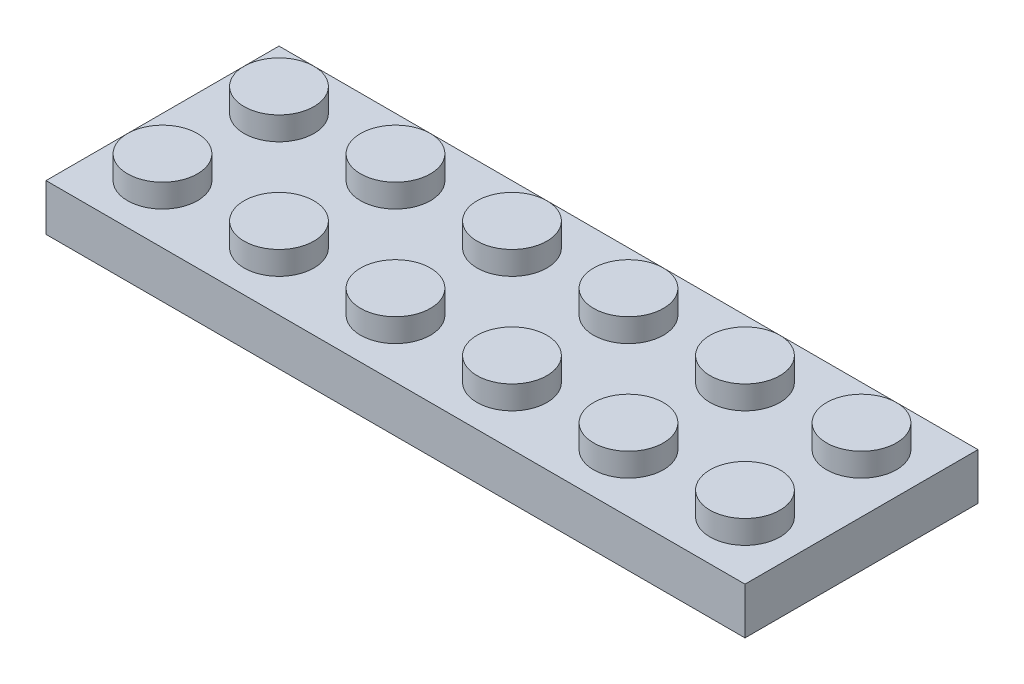
from build123d import *

# Parameters (mm, degrees)
SKETCH1_R              = 1.5
BOSS_EXTRUDE1_DEPTH    = 2
BOSS_EXTRUDE1_2_DEPTH  = 2
BOSS_EXTRUDE1_3_DEPTH  = 2
BOSS_EXTRUDE1_4_DEPTH  = 2
BOSS_EXTRUDE1_5_DEPTH  = 2
BOSS_EXTRUDE1_6_DEPTH  = 2
BOSS_EXTRUDE1_7_DEPTH  = 2
BOSS_EXTRUDE1_8_DEPTH  = 2
BOSS_EXTRUDE1_9_DEPTH  = 2
BOSS_EXTRUDE1_10_DEPTH = 2
BOSS_EXTRUDE1_11_DEPTH = 2
BOSS_EXTRUDE1_12_DEPTH = 2
SKETCH1_3_W            = 30
SKETCH1_3_H            = 10
BOSS_EXTRUDE2_DEPTH    = 1
SKETCH1_4_W            = 30
SKETCH1_4_H            = 10
SKETCH1_4_W_2          = 28
SKETCH1_4_H_2          = 8
SKETCH1_4_R            = 2.035533906
SKETCH1_4_R_2          = 1.5
BOSS_EXTRUDE3_DEPTH    = 1


with BuildPart() as part:
    # Sketch1 → Boss-Extrude1 (new body)
    with BuildSketch(Plane(origin=(0, 0, 0), x_dir=(1, 0, 0), z_dir=(0, 1, 0))):
        with Locations((-12.5, 2.5)):
            Circle(SKETCH1_R)
    extrude(amount=BOSS_EXTRUDE1_DEPTH)



with BuildPart() as body_2:
    # Sketch1 → Boss-Extrude1 2 (new body)
    with BuildSketch(Plane(origin=(0, 0, 0), x_dir=(1, 0, 0), z_dir=(0, 1, 0))):
        with Locations((-7.5, 2.5)):
            Circle(SKETCH1_R)
    extrude(amount=BOSS_EXTRUDE1_2_DEPTH)


with BuildPart() as body_3:
    # Sketch1 → Boss-Extrude1 3 (new body)
    with BuildSketch(Plane(origin=(0, 0, 0), x_dir=(1, 0, 0), z_dir=(0, 1, 0))):
        with Locations((-12.5, -2.5)):
            Circle(SKETCH1_R)
    extrude(amount=BOSS_EXTRUDE1_3_DEPTH)


with BuildPart() as body_4:
    # Sketch1 → Boss-Extrude1 4 (new body)
    with BuildSketch(Plane(origin=(0, 0, 0), x_dir=(1, 0, 0), z_dir=(0, 1, 0))):
        with Locations((-2.5, 2.5)):
            Circle(SKETCH1_R)
    extrude(amount=BOSS_EXTRUDE1_4_DEPTH)


with BuildPart() as body_5:
    # Sketch1 → Boss-Extrude1 5 (new body)
    with BuildSketch(Plane(origin=(0, 0, 0), x_dir=(1, 0, 0), z_dir=(0, 1, 0))):
        with Locations((2.5, 2.5)):
            Circle(SKETCH1_R)
    extrude(amount=BOSS_EXTRUDE1_5_DEPTH)


with BuildPart() as body_6:
    # Sketch1 → Boss-Extrude1 6 (new body)
    with BuildSketch(Plane(origin=(0, 0, 0), x_dir=(1, 0, 0), z_dir=(0, 1, 0))):
        with Locations((-7.5, -2.5)):
            Circle(SKETCH1_R)
    extrude(amount=BOSS_EXTRUDE1_6_DEPTH)


with BuildPart() as body_7:
    # Sketch1 → Boss-Extrude1 7 (new body)
    with BuildSketch(Plane(origin=(0, 0, 0), x_dir=(1, 0, 0), z_dir=(0, 1, 0))):
        with Locations((7.5, 2.5)):
            Circle(SKETCH1_R)
    extrude(amount=BOSS_EXTRUDE1_7_DEPTH)


with BuildPart() as body_8:
    # Sketch1 → Boss-Extrude1 8 (new body)
    with BuildSketch(Plane(origin=(0, 0, 0), x_dir=(1, 0, 0), z_dir=(0, 1, 0))):
        with Locations((-2.5, -2.5)):
            Circle(SKETCH1_R)
    extrude(amount=BOSS_EXTRUDE1_8_DEPTH)


with BuildPart() as body_9:
    # Sketch1 → Boss-Extrude1 9 (new body)
    with BuildSketch(Plane(origin=(0, 0, 0), x_dir=(1, 0, 0), z_dir=(0, 1, 0))):
        with Locations((12.5, 2.5)):
            Circle(SKETCH1_R)
    extrude(amount=BOSS_EXTRUDE1_9_DEPTH)


with BuildPart() as body_10:
    # Sketch1 → Boss-Extrude1 10 (new body)
    with BuildSketch(Plane(origin=(0, 0, 0), x_dir=(1, 0, 0), z_dir=(0, 1, 0))):
        with Locations((2.5, -2.5)):
            Circle(SKETCH1_R)
    extrude(amount=BOSS_EXTRUDE1_10_DEPTH)


with BuildPart() as body_11:
    # Sketch1 → Boss-Extrude1 11 (new body)
    with BuildSketch(Plane(origin=(0, 0, 0), x_dir=(1, 0, 0), z_dir=(0, 1, 0))):
        with Locations((7.5, -2.5)):
            Circle(SKETCH1_R)
    extrude(amount=BOSS_EXTRUDE1_11_DEPTH)


with BuildPart() as body_12:
    # Sketch1 → Boss-Extrude1 12 (new body)
    with BuildSketch(Plane(origin=(0, 0, 0), x_dir=(1, 0, 0), z_dir=(0, 1, 0))):
        with Locations((12.5, -2.5)):
            Circle(SKETCH1_R)
    extrude(amount=BOSS_EXTRUDE1_12_DEPTH)


with BuildPart() as part_1:
    add(part.part)

    add(body_2.part)  # Boss-Extrude2 merges body 2

    add(body_3.part)  # Boss-Extrude2 merges body 3

    add(body_4.part)  # Boss-Extrude2 merges body 4

    add(body_5.part)  # Boss-Extrude2 merges body 5

    add(body_6.part)  # Boss-Extrude2 merges body 6

    add(body_7.part)  # Boss-Extrude2 merges body 7

    add(body_8.part)  # Boss-Extrude2 merges body 8

    add(body_9.part)  # Boss-Extrude2 merges body 9

    add(body_10.part)  # Boss-Extrude2 merges body 10

    add(body_11.part)  # Boss-Extrude2 merges body 11

    add(body_12.part)  # Boss-Extrude2 merges body 12
    # Sketch1_3 → Boss-Extrude2 (add)
    with BuildSketch(Plane(origin=(0, 0, 0), x_dir=(1, 0, 0), z_dir=(0, 1, 0))):
        Rectangle(SKETCH1_3_W, SKETCH1_3_H)
    extrude(amount=BOSS_EXTRUDE2_DEPTH)

    # Sketch1_4 → Boss-Extrude3 (add)
    # profile 1 of 6: a face of its own
    with BuildSketch(Plane(origin=(0, 0, 0), x_dir=(1, 0, 0), z_dir=(0, 1, 0))):
        Rectangle(SKETCH1_4_W, SKETCH1_4_H)
        Rectangle(SKETCH1_4_W_2, SKETCH1_4_H_2, mode=Mode.SUBTRACT)
    # profile 2 of 6: a face of its own
    with BuildSketch(Plane(origin=(0, 0, 0), x_dir=(1, 0, 0), z_dir=(0, 1, 0))):
        with Locations((-10, 0)):
            Circle(SKETCH1_4_R)
        with Locations((-10, 0)):
            Circle(SKETCH1_4_R_2, mode=Mode.SUBTRACT)
    # profile 3 of 6: a face of its own
    with BuildSketch(Plane(origin=(0, 0, 0), x_dir=(1, 0, 0), z_dir=(0, 1, 0))):
        with Locations((-5, 0)):
            Circle(SKETCH1_4_R)
        with Locations((-5, 0)):
            Circle(SKETCH1_4_R_2, mode=Mode.SUBTRACT)
    # profile 4 of 6: a face of its own
    with BuildSketch(Plane(origin=(0, 0, 0), x_dir=(1, 0, 0), z_dir=(0, 1, 0))):
        Circle(SKETCH1_4_R)
        Circle(SKETCH1_4_R_2, mode=Mode.SUBTRACT)
    # profile 5 of 6: a face of its own
    with BuildSketch(Plane(origin=(0, 0, 0), x_dir=(1, 0, 0), z_dir=(0, 1, 0))):
        with Locations((5, 0)):
            Circle(SKETCH1_4_R)
        with Locations((5, 0)):
            Circle(SKETCH1_4_R_2, mode=Mode.SUBTRACT)
    # profile 6 of 6: a face of its own
    with BuildSketch(Plane(origin=(0, 0, 0), x_dir=(1, 0, 0), z_dir=(0, 1, 0))):
        with Locations((10, 0)):
            Circle(SKETCH1_4_R)
        with Locations((10, 0)):
            Circle(SKETCH1_4_R_2, mode=Mode.SUBTRACT)
    extrude(amount=-BOSS_EXTRUDE3_DEPTH)


solid = part_1.part
